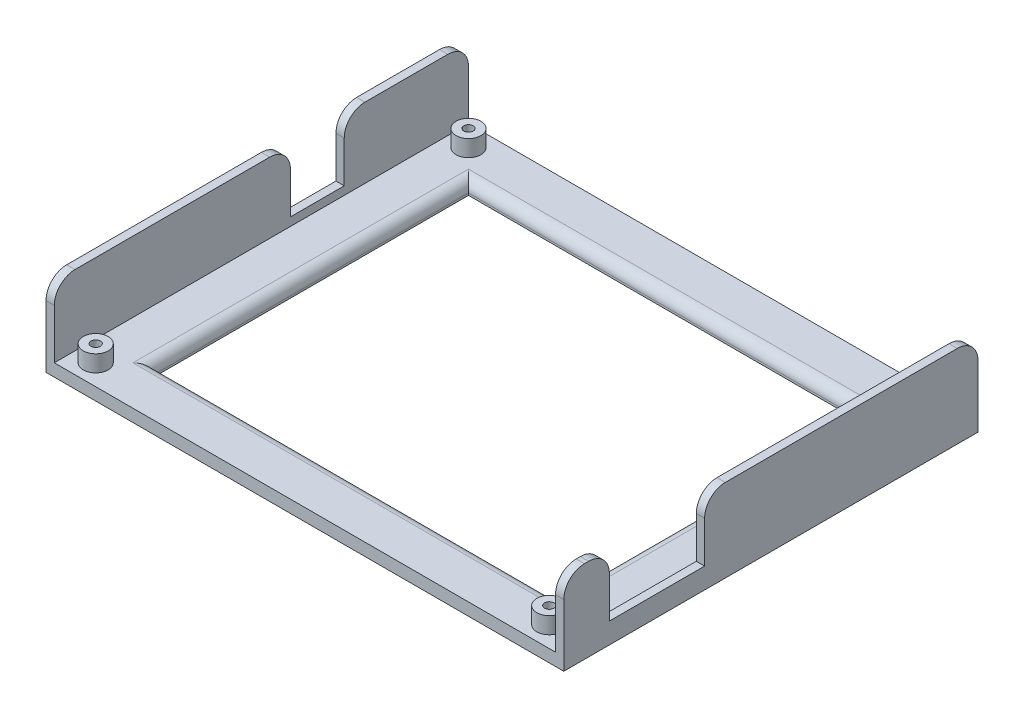
from build123d import *

# Parameters (mm, degrees)
SKETCH1_W           = 125
SKETCH1_H           = 100
BOSS_EXTRUDE1_DEPTH = 3
SKETCH2_W           = 2
SKETCH2_H           = 100
BOSS_EXTRUDE2_DEPTH = 17
SKETCH3_R           = 3
BOSS_EXTRUDE4_DEPTH = 4
SKETCH4_W           = 13
SKETCH4_H           = 15
CUT_EXTRUDE1_DEPTH  = 2
SKETCH5_W           = 23
SKETCH5_H           = 15
CUT_EXTRUDE2_DEPTH  = 2
SKETCH6_R           = 1.125
CUT_EXTRUDE3_DEPTH  = 22
FILLET1_R           = 5
FILLET2_R           = 5
SKETCH7_W           = 97.170339499
SKETCH7_H           = 76
CUT_EXTRUDE4_DEPTH  = 22
FILLET3_R           = 2.5


with BuildPart() as part:
    # Sketch1 → Boss-Extrude1 (new body)
    with BuildSketch(Plane(origin=(0, 0, 0), x_dir=(1, 0, 0), z_dir=(0, 1, 0))):
        with Locations((14.321748602, -19.715443405)):
            Rectangle(SKETCH1_W, SKETCH1_H)
    extrude(amount=BOSS_EXTRUDE1_DEPTH)

    # Sketch2 → Boss-Extrude2 (add)
    with BuildSketch(Plane(origin=(0, 3, 0), x_dir=(1, 0, 0), z_dir=(0, 1, 0))):
        with Locations((75.821748602, -19.715443405)):
            Rectangle(SKETCH2_W, SKETCH2_H)
        with Locations((-47.178251398, -19.715443405)):
            Rectangle(SKETCH2_W, SKETCH2_H)
    extrude(amount=BOSS_EXTRUDE2_DEPTH)

    # Sketch3 → Boss-Extrude4 (add)
    with BuildSketch(Plane(origin=(0, 3, 0), x_dir=(1, 0, 0), z_dir=(0, 1, 0))):
        with Locations((-41.178251398, -64.715443405)):
            Circle(SKETCH3_R)
        with Locations((-41.178251398, 25.284556595)):
            Circle(SKETCH3_R)
        with Locations((68.315618549, 25.284556595)):
            Circle(SKETCH3_R)
        with Locations((68.315618549, -64.715443405)):
            Circle(SKETCH3_R)
    extrude(amount=BOSS_EXTRUDE4_DEPTH)

    # Sketch4 → Cut-Extrude1 (cut)
    with BuildSketch(Plane.ZY.offset(48.178251398)):
        with Locations((6.215443405, 12.5)):
            Rectangle(SKETCH4_W, SKETCH4_H)
    extrude(amount=-CUT_EXTRUDE1_DEPTH, mode=Mode.SUBTRACT)

    # Sketch5 → Cut-Extrude2 (cut)
    with BuildSketch(Plane(origin=(76.821748602, 0, 0), x_dir=(0, 0, -1), z_dir=(1, 0, 0))):
        with Locations((-47.215443405, 12.5)):
            Rectangle(SKETCH5_W, SKETCH5_H)
    extrude(amount=-CUT_EXTRUDE2_DEPTH, mode=Mode.SUBTRACT)

    # Sketch6 → Cut-Extrude3 (cut)
    with BuildSketch(Plane(origin=(0, 7, 0), x_dir=(1, 0, 0), z_dir=(0, 1, 0))):
        with Locations((-41.178251398, -64.715443405)):
            Circle(SKETCH6_R)
        with Locations((-41.178251398, 25.284556595)):
            Circle(SKETCH6_R)
        with Locations((68.315618549, -64.715443405)):
            Circle(SKETCH6_R)
        with Locations((68.315618549, 25.284556595)):
            Circle(SKETCH6_R)
    extrude(amount=-CUT_EXTRUDE3_DEPTH, mode=Mode.SUBTRACT)

    # Fillet1
    fillet1_edges = [part.edges().sort_by_distance(p)[0] for p in [
        (75.821748602, 20, 69.715443405),
        (-47.178251398, 20, 69.715443405),
        (-47.178251398, 20, -30.284556595),
        (75.821748602, 20, -30.284556595),
    ]]
    fillet(fillet1_edges, radius=FILLET1_R)

    # Fillet2
    fillet2_edges = [part.edges().sort_by_distance(p)[0] for p in [
        (-47.178251398, 20, -0.284556595),
        (-47.178251398, 20, 12.715443405),
        (75.821748602, 20, 58.715443405),
        (75.821748602, 20, 35.715443405),
    ]]
    fillet(fillet2_edges, radius=FILLET2_R)

    # Sketch7 → Cut-Extrude4 (cut)
    with BuildSketch(Plane(origin=(0, 3, 0), x_dir=(1, 0, 0), z_dir=(0, 1, 0))):
        with Locations((14.406918352, -19.715443405)):
            Rectangle(SKETCH7_W, SKETCH7_H)
    extrude(amount=-CUT_EXTRUDE4_DEPTH, mode=Mode.SUBTRACT)

    # Fillet3
    fillet3_edges = [part.edges().sort_by_distance(p)[0] for p in [
        (62.992088101, 3, 19.715443405),
        (14.406918351, 3, -18.284556595),
        (-34.178251398, 3, 19.715443405),
        (14.406918351, 3, 57.715443405),
    ]]
    fillet(fillet3_edges, radius=FILLET3_R)


solid = part.part
